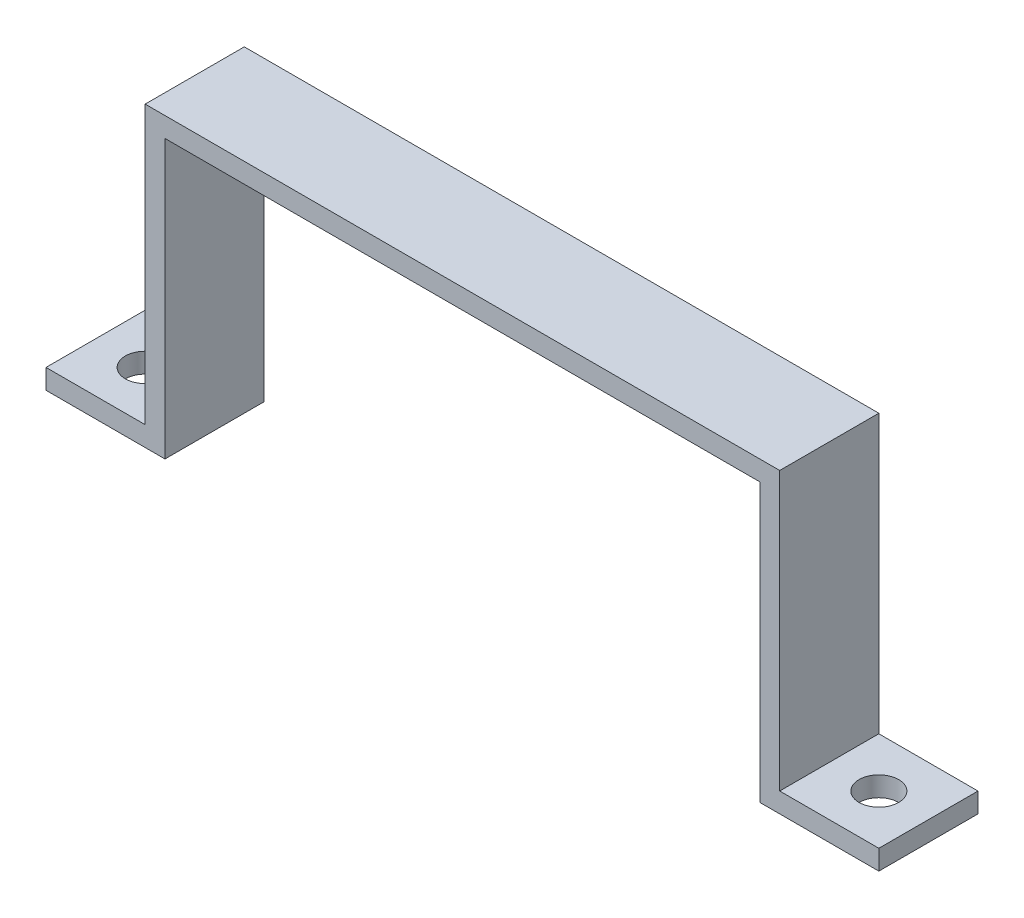
from build123d import *

# Parameters (mm, degrees)
BOSS_EXTRUDE1_DEPTH = 10
SKETCH2_R           = 2
CUT_EXTRUDE2_DEPTH  = 10
SKETCH3_W           = 10
SKETCH3_H           = 10
CUT_EXTRUDE3_DEPTH  = 10


with BuildPart() as part:
    # Sketch1 → Boss-Extrude1 (new body)
    with BuildSketch(Plane.XY):
        Polygon((-57.4285121, -21.353337692), (-37.4285121, -21.353337692), (-35.4285121, -21.353337692), (-35.4285121, 6.646662308), (24.5714879, 6.646662308), (24.5714879, -21.353337692), (26.5714879, -21.353337692), (46.5714879, -21.353337692), (46.5714879, -19.353337692), (26.5714879, -19.353337692), (26.5714879, 8.646662308), (24.5714879, 8.646662308), (-35.4285121, 8.646662308), (-37.4285121, 8.646662308), (-37.4285121, -19.353337692), (-57.4285121, -19.353337692), align=None)
    extrude(amount=BOSS_EXTRUDE1_DEPTH)

    # Sketch2 → Cut-Extrude2 (cut)
    with BuildSketch(Plane(origin=(0, -19.353337692, 0), x_dir=(1, 0, 0), z_dir=(0, 1, 0))):
        with Locations((-42.4285121, -5)):
            Circle(SKETCH2_R)
        with Locations((31.5714879, -5)):
            Circle(SKETCH2_R)
    extrude(amount=-CUT_EXTRUDE2_DEPTH, mode=Mode.SUBTRACT)

    # Sketch3 → Cut-Extrude3 (cut)
    with BuildSketch(Plane(origin=(0, -19.353337692, 0), x_dir=(1, 0, 0), z_dir=(0, 1, 0))):
        with Locations((-52.4285121, -5)):
            Rectangle(SKETCH3_W, SKETCH3_H)
        with Locations((41.5714879, -5)):
            Rectangle(SKETCH3_W, SKETCH3_H)
    extrude(amount=-CUT_EXTRUDE3_DEPTH, mode=Mode.SUBTRACT)


solid = part.part
